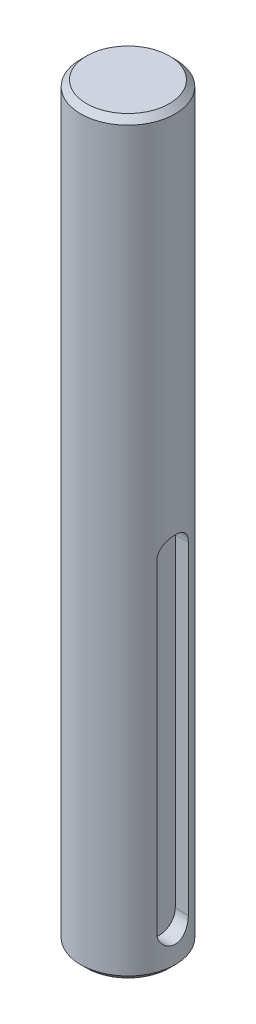
from build123d import *

# Parameters (mm, degrees)
SKETCH1_R           = 12
BOSS_EXTRUDE1_DEPTH = 190
CUT_EXTRUDE1_DEPTH  = 4
CHAMFER1_SIZE       = 1.5


with BuildPart() as part:
    # Sketch1 → Boss-Extrude1 (new body)
    with BuildSketch(Plane(origin=(0, 0, 0), x_dir=(1, 0, 0), z_dir=(0, 1, 0))):
        Circle(SKETCH1_R)
    extrude(amount=BOSS_EXTRUDE1_DEPTH)

    # Sketch2 → Cut-Extrude1 (cut)
    with BuildSketch(Plane(origin=(12, 0, 0), x_dir=(0, 0, -1), z_dir=(1, 0, 0))):
        with BuildLine():
            Line((4, 92), (4, 10))
            ThreePointArc((4, 10), (0, 6), (-4, 10))
            Line((-4, 10), (-4, 92))
            ThreePointArc((-4, 92), (0, 96), (4, 92))
        make_face()
    extrude(amount=-CUT_EXTRUDE1_DEPTH, mode=Mode.SUBTRACT)

    # Chamfer1
    chamfer1_edges = [part.edges().sort_by_distance(p)[0] for p in [
        (-12, 0, 0),
        (-12, 190, 0),
    ]]
    chamfer(chamfer1_edges, length=CHAMFER1_SIZE)


solid = part.part
